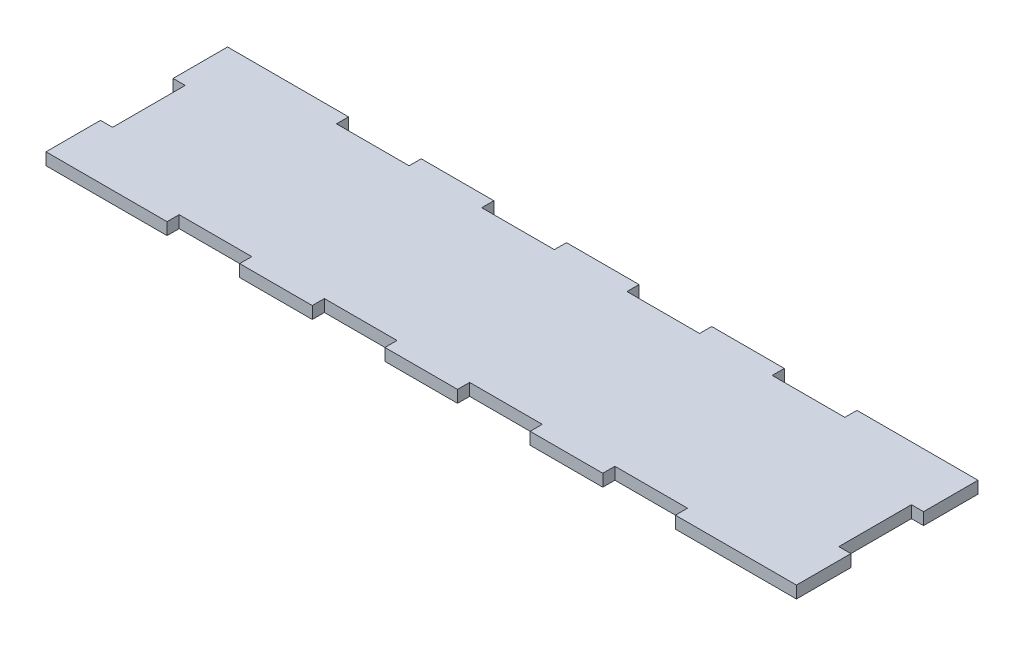
from build123d import *

# Parameters (mm, degrees)
ESQUISSE1_W                = 393.7
ESQUISSE1_H                = 95.25
BOSS_EXTRU_1_DEPTH         = 6.35
ESQUISSE2_W                = 38.1
ESQUISSE2_H                = 6.35
ENL_V_MAT_EXTRU_1_DEPTH    = 6.35
ESQUISSE3_W                = 38.1
ESQUISSE3_H                = 6.35
ENL_V_MAT_EXTRU_2_DEPTH    = 6.35
R_P_TITION_LIN_AIRE1_COUNT = 4
R_P_TITION_LIN_AIRE1_PITCH = 76.2
SYM_TRIE2_COPY_1_SKETCH_W  = 38.1
SYM_TRIE2_COPY_1_SKETCH_H  = 6.35
SYM_TRIE2_COPY_1_DEPTH     = 6.35
SYM_TRIE2_COPY_2_SKETCH_W  = 38.1
SYM_TRIE2_COPY_2_SKETCH_H  = 6.35
SYM_TRIE2_COPY_2_DEPTH     = 6.35
SYM_TRIE2_COPY_3_SKETCH_W  = 38.1
SYM_TRIE2_COPY_3_SKETCH_H  = 6.35
SYM_TRIE2_COPY_3_DEPTH     = 6.35


with BuildPart() as part:
    # Esquisse1 → Boss.-Extru.1 (new body)
    with BuildSketch(Plane(origin=(0, 0, 0), x_dir=(1, 0, 0), z_dir=(0, 1, 0))):
        Rectangle(ESQUISSE1_W, ESQUISSE1_H)
    extrude(amount=BOSS_EXTRU_1_DEPTH)

    # Esquisse2 → Enlèv. mat.-Extru.1 (cut)
    with BuildSketch(Plane.ZY.offset(196.85)):
        with Locations((0, 3.175)):
            Rectangle(ESQUISSE2_W, ESQUISSE2_H)
    enl_v_mat_extru_1 = extrude(amount=-ENL_V_MAT_EXTRU_1_DEPTH, mode=Mode.SUBTRACT)

    # Symétrie1: Enlèv. mat.-Extru.1 across plane
    add(enl_v_mat_extru_1.mirror(Plane(origin=(0, 0, 0), x_dir=(0, 0, 1), z_dir=(1, 0, 0))), mode=Mode.SUBTRACT)

    # Esquisse3 → Enlèv. mat.-Extru.2 (cut)
    with BuildSketch(Plane(origin=(0, 0, -47.625), x_dir=(-1, 0, 0), z_dir=(0, 0, -1))):
        with Locations((114.3, 3.175)):
            Rectangle(ESQUISSE3_W, ESQUISSE3_H)
    enl_v_mat_extru_2 = extrude(amount=-ENL_V_MAT_EXTRU_2_DEPTH, mode=Mode.SUBTRACT)

    # Répétition linéaire1: Enlèv. mat.-Extru.2 ×4
    with Locations(*[(i * R_P_TITION_LIN_AIRE1_PITCH, 0, 0) for i in range(1, R_P_TITION_LIN_AIRE1_COUNT)]):
        add(enl_v_mat_extru_2, mode=Mode.SUBTRACT)

    # Symétrie2: Enlèv. mat.-Extru.2 across plane
    add(enl_v_mat_extru_2.mirror(Plane.XY), mode=Mode.SUBTRACT)

    # Symétrie2 copy 1 sketch → Symétrie2 copy 1 (cut)
    with BuildSketch(Plane(origin=(76.2, 0, 47.625), x_dir=(-1, 0, 0), z_dir=(0, 0, 1))):
        with Locations((114.3, -3.175)):
            Rectangle(SYM_TRIE2_COPY_1_SKETCH_W, SYM_TRIE2_COPY_1_SKETCH_H)
    extrude(amount=-SYM_TRIE2_COPY_1_DEPTH, mode=Mode.SUBTRACT)

    # Symétrie2 copy 2 sketch → Symétrie2 copy 2 (cut)
    with BuildSketch(Plane(origin=(152.4, 0, 47.625), x_dir=(-1, 0, 0), z_dir=(0, 0, 1))):
        with Locations((114.3, -3.175)):
            Rectangle(SYM_TRIE2_COPY_2_SKETCH_W, SYM_TRIE2_COPY_2_SKETCH_H)
    extrude(amount=-SYM_TRIE2_COPY_2_DEPTH, mode=Mode.SUBTRACT)

    # Symétrie2 copy 3 sketch → Symétrie2 copy 3 (cut)
    with BuildSketch(Plane(origin=(228.6, 0, 47.625), x_dir=(-1, 0, 0), z_dir=(0, 0, 1))):
        with Locations((114.3, -3.175)):
            Rectangle(SYM_TRIE2_COPY_3_SKETCH_W, SYM_TRIE2_COPY_3_SKETCH_H)
    extrude(amount=-SYM_TRIE2_COPY_3_DEPTH, mode=Mode.SUBTRACT)


solid = part.part
